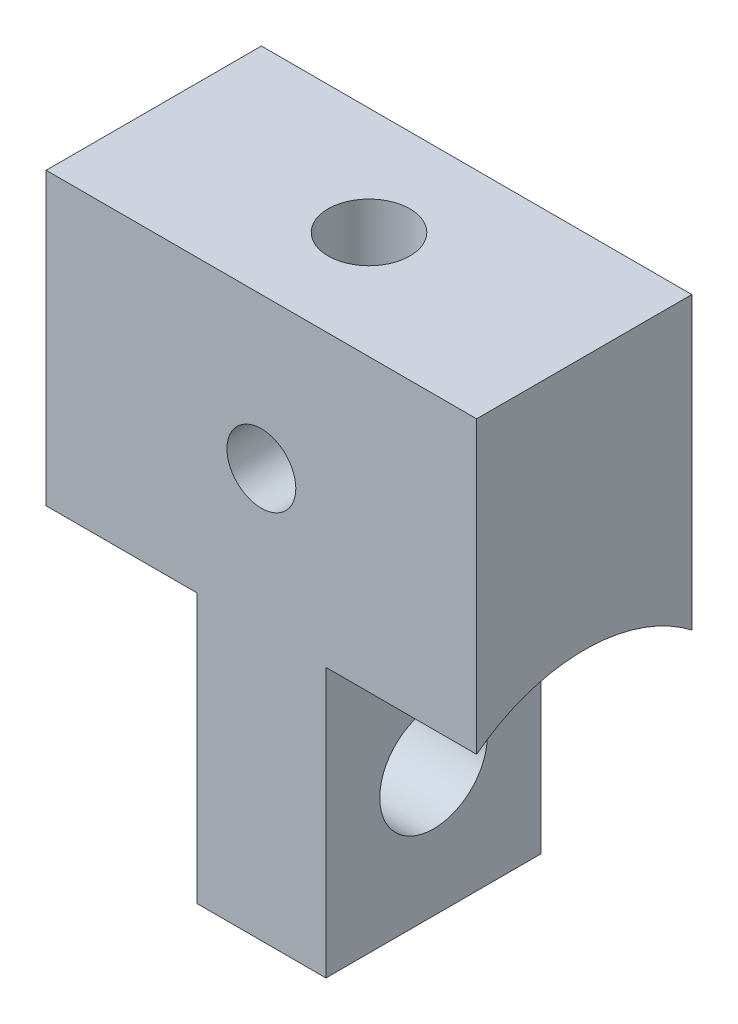
from build123d import *

# Parameters (mm, degrees)
SKETCH1_W           = 10
SKETCH1_H           = 13
SKETCH1_R           = 0.8
BOSS_EXTRUDE1_DEPTH = 5
CUT_EXTRUDE2_DEPTH  = 3.5
SKETCH4_R           = 1.25
CUT_EXTRUDE3_DEPTH  = 7.5
SKETCH5_R           = 0.95
CUT_EXTRUDE4_DEPTH  = 3


with BuildPart() as part:
    # Sketch1 → Boss-Extrude1 (new body)
    with BuildSketch(Plane.XY):
        Rectangle(SKETCH1_W, SKETCH1_H)
        with Locations((0, 3)):
            Circle(SKETCH1_R, mode=Mode.SUBTRACT)
    extrude(amount=BOSS_EXTRUDE1_DEPTH)

    # Sketch3 → Cut-Extrude2 (cut)
    with BuildSketch(Plane.ZY.offset(5)):
        with BuildLine():
            Line((-1.6, -3.5), (-1.6, -7.6))
            Line((-1.6, -7.6), (6.6, -7.6))
            Line((6.6, -7.6), (6.6, -3.5))
            ThreePointArc((6.6, -3.5), (2.5, 0.6), (-1.6, -3.5))
        make_face()
    cut_extrude2 = extrude(amount=-CUT_EXTRUDE2_DEPTH, mode=Mode.SUBTRACT)

    # Mirror1: Cut-Extrude2 across plane
    add(cut_extrude2.mirror(Plane(origin=(0, 0, 0), x_dir=(0, 0, 1), z_dir=(1, 0, 0))), mode=Mode.SUBTRACT)

    # Sketch4 → Cut-Extrude3 (cut, through all)
    with BuildSketch(Plane.ZY.offset(1.5)):
        with Locations((2.5, -3.5)):
            Circle(SKETCH4_R)
    extrude(amount=-CUT_EXTRUDE3_DEPTH, mode=Mode.SUBTRACT)

    # Sketch5 → Cut-Extrude4 (cut)
    with BuildSketch(Plane(origin=(0, 6.5, 0), x_dir=(1, 0, 0), z_dir=(0, 1, 0))):
        with Locations((0, -2.5)):
            Circle(SKETCH5_R)
    extrude(amount=-CUT_EXTRUDE4_DEPTH, mode=Mode.SUBTRACT)


solid = part.part
